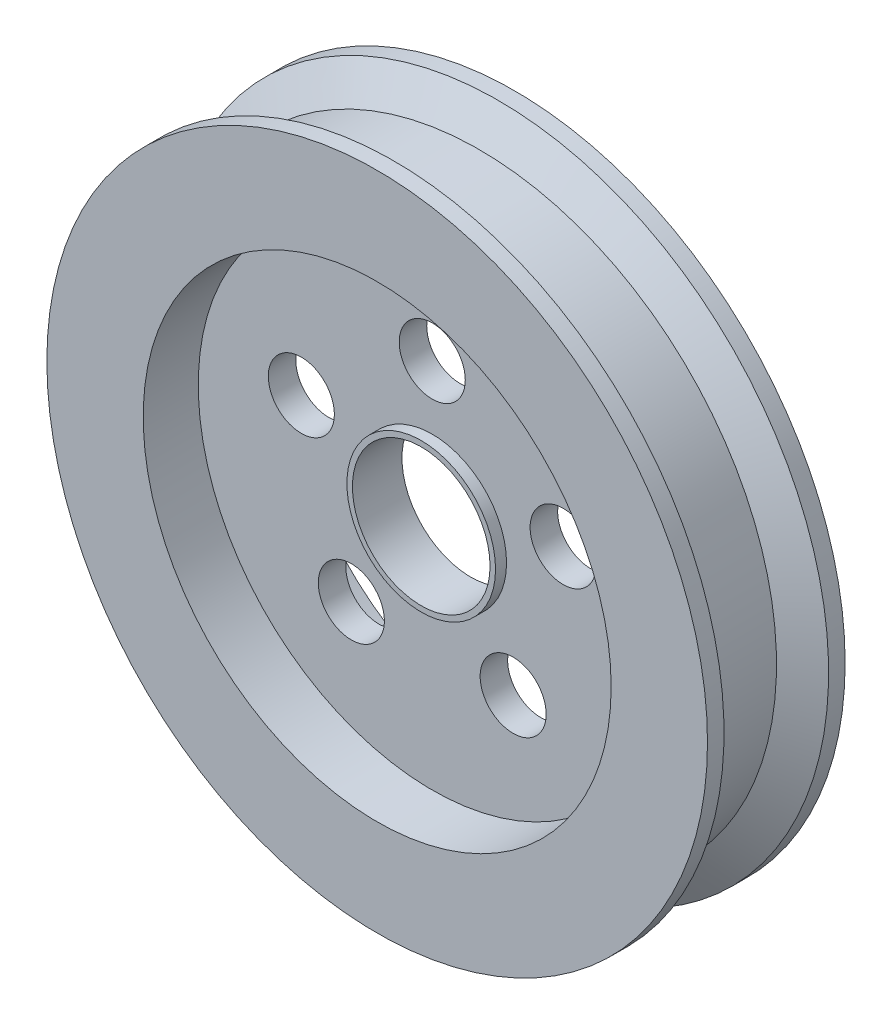
from build123d import *

# Parameters (mm, degrees)
SKETCH1_R                = 60
SKETCH1_R_2              = 12.5
BOSS_EXTRUDE1_DEPTH      = 12.5
SKETCH2_R                = 42.5
CUT_EXTRUDE1_DEPTH       = 10
SKETCH3_R                = 6
CUT_EXTRUDE2_DEPTH       = 16
CIRPATTERN1_COUNT        = 5
SKETCH5_R                = 13.5
SKETCH5_R_2              = 12.5
BOSS_EXTRUDE2_DEPTH      = 2
BOSS_EXTRUDE2_DEPTH_BACK = 7


with BuildPart() as part:
    # Sketch1 → Boss-Extrude1 (new body, symmetric)
    with BuildSketch(Plane.XY):
        Circle(SKETCH1_R)
        Circle(SKETCH1_R_2, mode=Mode.SUBTRACT)
    extrude(amount=BOSS_EXTRUDE1_DEPTH, both=True)

    # Sketch2 → Cut-Extrude1 (cut)
    with BuildSketch(Plane.XY.offset(12.5)):
        Circle(SKETCH2_R)
    cut_extrude1 = extrude(amount=-CUT_EXTRUDE1_DEPTH, mode=Mode.SUBTRACT)

    # Mirror1: Cut-Extrude1 across plane
    add(cut_extrude1.mirror(Plane.XY), mode=Mode.SUBTRACT)

    # Sketch3 → Cut-Extrude2 (cut, through all)
    with BuildSketch(Plane.XY.offset(2.5)):
        with Locations((0, 25)):
            Circle(SKETCH3_R)
    cut_extrude2 = extrude(amount=-CUT_EXTRUDE2_DEPTH, mode=Mode.SUBTRACT)

    # CirPattern1: Cut-Extrude2 ×5 about axis
    cirpattern1_axis = Axis((0, 0, 0), (0, 0, 1))
    for i in range(1, CIRPATTERN1_COUNT):
        add(cut_extrude2.rotate(cirpattern1_axis, i * 360 / CIRPATTERN1_COUNT), mode=Mode.SUBTRACT)

    # Sketch4 → Cut-Revolve1 (revolve, cut)
    with BuildSketch(Plane(origin=(0, 0, 0), x_dir=(1, 0, 0), z_dir=(0, 1, 0))):
        Polygon((60, 9.5), (54, 6.035898385), (54, -6.035898385), (60, -9.5), align=None)
    revolve(axis=Axis((0, 0, -27.814939566), (0, 0, 1)), mode=Mode.SUBTRACT)

    # Sketch5 → Boss-Extrude2 (add, two sides)
    with BuildSketch(Plane.XY.offset(2.5)) as boss_extrude2_sk:
        Circle(SKETCH5_R)
        Circle(SKETCH5_R_2, mode=Mode.SUBTRACT)
    extrude(amount=BOSS_EXTRUDE2_DEPTH)
    extrude(boss_extrude2_sk.sketch, amount=-BOSS_EXTRUDE2_DEPTH_BACK)


solid = part.part
